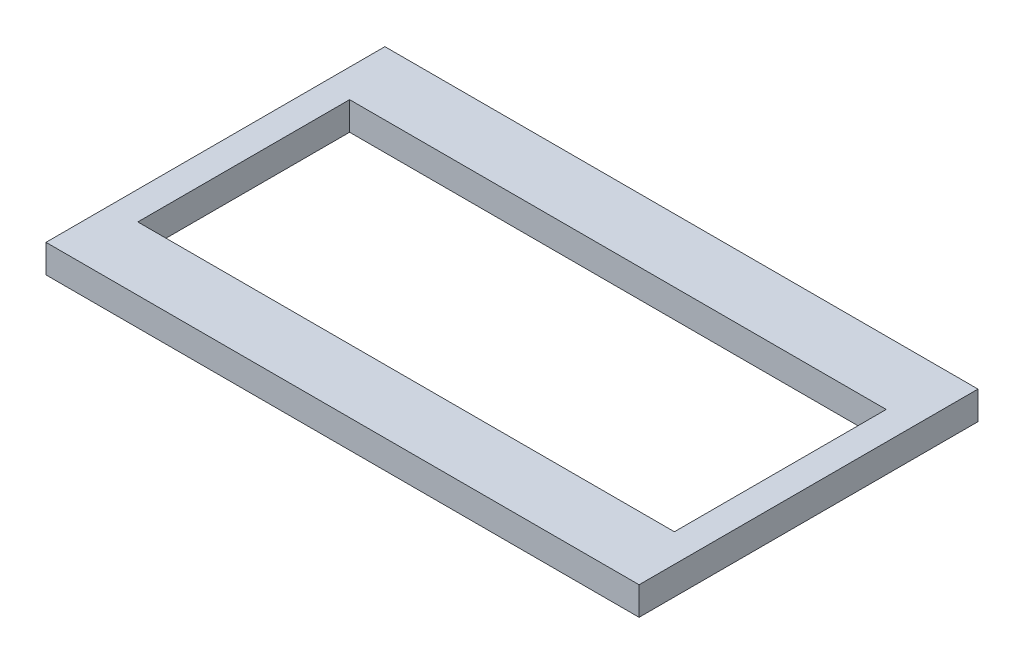
from build123d import *

# Parameters (mm, degrees)
SKETCH3_W           = 106.68
SKETCH3_H           = 60.96
SKETCH3_W_2         = 96.52
SKETCH3_H_2         = 38.1
BOSS_EXTRUDE1_DEPTH = 5.08


with BuildPart() as part:
    # Sketch3 → Boss-Extrude1 (new body)
    with BuildSketch(Plane(origin=(0, 0, 0), x_dir=(1, 0, 0), z_dir=(0, 1, 0))):
        Rectangle(SKETCH3_W, SKETCH3_H)
        Rectangle(SKETCH3_W_2, SKETCH3_H_2, mode=Mode.SUBTRACT)
    extrude(amount=BOSS_EXTRUDE1_DEPTH)


solid = part.part
